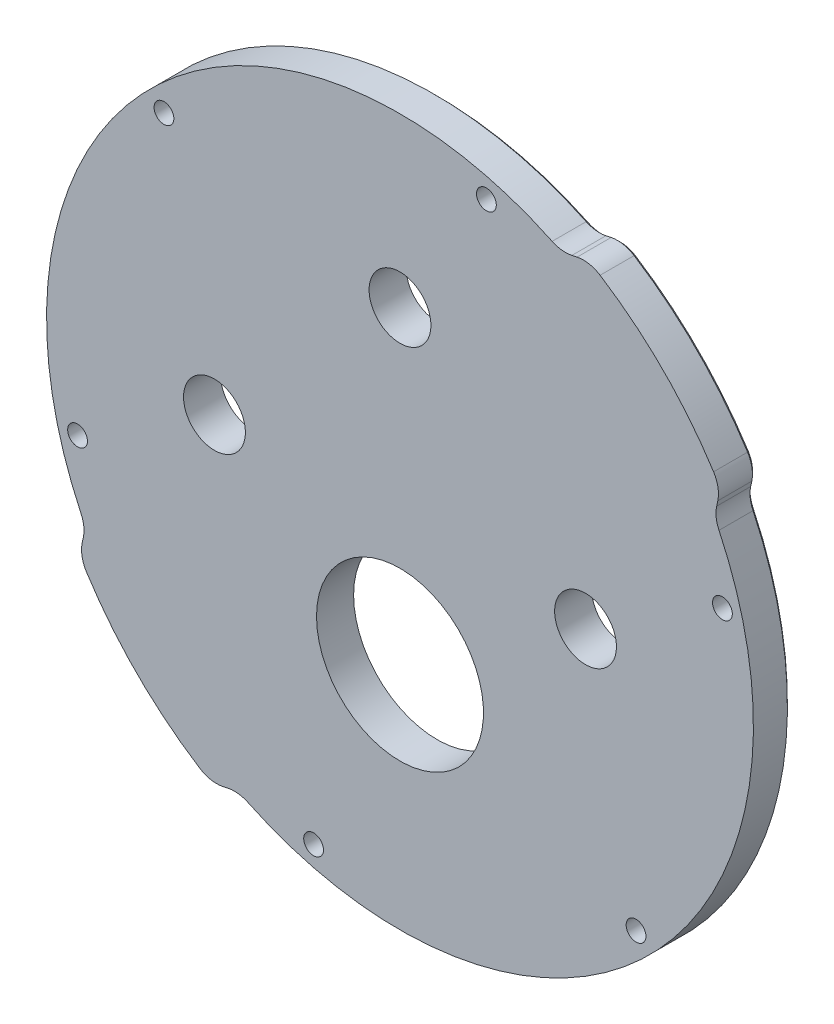
from build123d import *

# Parameters (mm, degrees)
EXTRUDE_1_DEPTH             = 6
CUT_EXTRUDE_1_DEPTH         = 7
HOLE_WIZARD_M24_1_D         = 27
HOLE_WIZARD_M24_1_DEPTH     = 6
HOLE_WIZARD_10_0_10_1_D     = 10
HOLE_WIZARD_10_0_10_1_DEPTH = 6
HOLE_WIZARD_3_2_3_2_1_D     = 3.2
HOLE_WIZARD_3_2_3_2_1_DEPTH = 6
FILLET_1_R                  = 5
CHAMFER_1_SIZE              = 0.5


with BuildPart() as part:
    # 草图1 → 凸台-拉伸1 (new body)
    with BuildSketch(Plane.XY.offset(6)):
        with BuildLine():
            Line((-50.844308234, -26.095570892), (-51.795328938, -30.582125502))
            ThreePointArc((-51.795328938, -30.582125502), (42.532472888, -42.532472888), (30.582125502, 51.795328938))
            Line((30.582125502, 51.795328938), (26.095570892, 50.844308234))
            ThreePointArc((26.095570892, 50.844308234), (-40.411152545, 40.411152545), (-50.844308234, -26.095570892))
        make_face()
    extrude(amount=-EXTRUDE_1_DEPTH)

    # 草图2 → 切除-拉伸1 (cut, through all)
    with BuildSketch(Plane(origin=(0, 0, 0), x_dir=(-1, 0, 0), z_dir=(0, 0, -1))):
        with BuildLine():
            Line((30.582125502, -51.795328938), (26.095570892, -50.844308234))
            ThreePointArc((26.095570892, -50.844308234), (-40.411152545, -40.411152545), (-50.844308234, 26.095570892))
            Line((-50.844308234, 26.095570892), (-51.795328938, 30.582125502))
            ThreePointArc((-51.795328938, 30.582125502), (-42.532472888, -42.532472888), (30.582125502, -51.795328938))
        make_face()
    extrude(amount=-CUT_EXTRUDE_1_DEPTH, mode=Mode.SUBTRACT)

    # M24 间隙孔1
    with Locations(Plane(origin=(0, 0, 0), x_dir=(-1, 0, 0), z_dir=(0, 0, -1))):
        with Locations((0, -20)):
            Hole(HOLE_WIZARD_M24_1_D / 2, depth=HOLE_WIZARD_M24_1_DEPTH)

    # Ø10.0 (10) 直径孔1
    with Locations(Plane(origin=(0, 0, 0), x_dir=(-1, 0, 0), z_dir=(0, 0, -1))):
        with Locations((0, 30), (-30, 0), (30, 0)):
            Hole(HOLE_WIZARD_10_0_10_1_D / 2, depth=HOLE_WIZARD_10_0_10_1_DEPTH)

    # Ø3.2 (3.2) 直径孔1
    with Locations(Plane(origin=(0, 0, 0), x_dir=(-1, 0, 0), z_dir=(0, 0, -1))):
        with Locations((38.166088515, 38.166088515), (13.969757959, -52.135846474), (-13.969757959, 52.135846474), (-52.135846474, 13.969757959), (-38.166088515, -38.166088515), (52.135846474, -13.969757959)):
            Hole(HOLE_WIZARD_3_2_3_2_1_D / 2, depth=HOLE_WIZARD_3_2_3_2_1_DEPTH)

    # 圆角1
    fillet_1_edges = [part.edges().sort_by_distance(p)[0] for p in [
        (-30.582125502, -51.795328938, 3),
        (51.795328938, 30.582125502, 3),
        (50.844308234, 26.095570892, 3),
        (-26.095570892, -50.844308234, 3),
        (26.095570892, 50.844308234, 3),
        (30.582125502, 51.795328938, 3),
        (-51.795328938, -30.582125502, 3),
        (-50.844308234, -26.095570892, 3),
    ]]
    fillet(fillet_1_edges, radius=FILLET_1_R)

    # 倒角1
    chamfer_1_edges = [part.edges().sort_by_distance(p)[0] for p in [
        (51.409995233, 30.560581919, 0),
        (-30.560581919, -51.409995233, 0),
        (30.560581919, 51.409995233, 0),
        (-26.167497672, -51.130344697, 0),
        (51.130344697, 26.167497672, 0),
        (26.167497672, 51.130344697, 0),
        (-51.130344697, -26.167497672, 0),
        (40.411152545, -40.411152545, 0),
        (-28.212098099, -51.292951206, 0),
        (42.532472888, 42.532472888, 0),
        (28.212098099, 51.292951206, 0),
        (51.292951206, 28.212098099, 0),
        (-42.532472888, -42.532472888, 0),
        (-51.292951206, -28.212098099, 0),
        (-40.411152545, 40.411152545, 0),
        (-51.409995233, -30.560581919, 0),
    ]]
    chamfer(chamfer_1_edges, length=CHAMFER_1_SIZE)


solid = part.part
